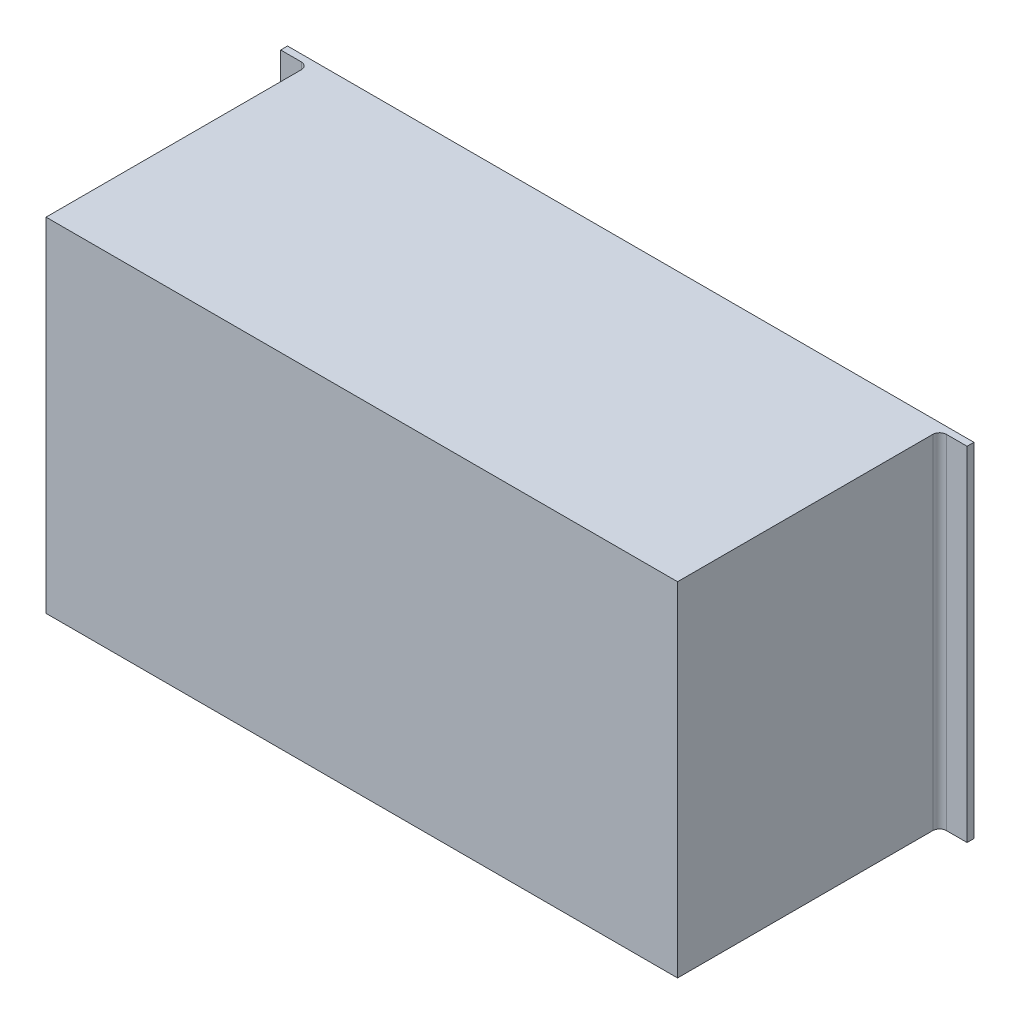
from build123d import *

# Parameters (mm, degrees)
IZIM1_W                     = 920
IZIM1_H                     = 500
Y_KSEKLIK_EKSTR_ZYON1_DEPTH = 380
BO_ALTMA1_T                 = -0.6
IZIM2_W                     = 920
IZIM2_H                     = 500
Y_KSEKLIK_EKSTR_ZYON2_DEPTH = 1.8
IZIM3_W                     = 1000
IZIM3_H                     = 500
Y_KSEKLIK_EKSTR_ZYON3_DEPTH = 10
RADYUS1_R                   = 10
IZIM4_W                     = 918.8
IZIM4_H                     = 498.8
KES_EKSTR_ZYON1_DEPTH       = 5
RADYUS2_R                   = 20
IZIM5_W                     = 920
IZIM5_H                     = 500
KES_EKSTR_ZYON2_DEPTH       = 0.0001


with BuildPart() as part:
    # Çizim1 → Yükseklik-Ekstrüzyon1 (new body)
    with BuildSketch(Plane.XY):
        with Locations((460, 250)):
            Rectangle(IZIM1_W, IZIM1_H)
    extrude(amount=Y_KSEKLIK_EKSTR_ZYON1_DEPTH)

    # İç Boşaltma1
    bo_altma1_openings = [part.faces().sort_by_distance(p)[0] for p in [
        (460, 250, 380),
    ]]
    offset(amount=BO_ALTMA1_T, openings=bo_altma1_openings, kind=Kind.INTERSECTION)

    # Çizim2 → Yükseklik-Ekstrüzyon2 (add)
    with BuildSketch(Plane.XY.offset(380)):
        with Locations((460, 250)):
            Rectangle(IZIM2_W, IZIM2_H)
    extrude(amount=Y_KSEKLIK_EKSTR_ZYON2_DEPTH)

    # Çizim3 → Yükseklik-Ekstrüzyon3 (add)
    with BuildSketch(Plane(origin=(0, 0, 0), x_dir=(-1, 0, 0), z_dir=(0, 0, -1))):
        with Locations((-460, 250)):
            Rectangle(IZIM3_W, IZIM3_H)
    extrude(amount=Y_KSEKLIK_EKSTR_ZYON3_DEPTH)

    # Radyus1
    radyus1_edges = [part.edges().sort_by_distance(p)[0] for p in [
        (0, 250, 0),
        (920, 250, 0),
    ]]
    fillet(radyus1_edges, radius=RADYUS1_R)

    # Çizim4 → Kes-Ekstrüzyon1 (cut)
    with BuildSketch(Plane.XY.offset(0.6)):
        with Locations((460, 250)):
            Rectangle(IZIM4_W, IZIM4_H)
    extrude(amount=-KES_EKSTR_ZYON1_DEPTH, mode=Mode.SUBTRACT)

    # Radyus2
    radyus2_edges = [part.edges().sort_by_distance(p)[0] for p in [
        (919.4, 250, -4.4),
        (460, 0.6, -4.4),
        (0.6, 250, -4.4),
        (460, 499.4, -4.4),
    ]]
    fillet(radyus2_edges, radius=RADYUS2_R)

    # Çizim5 → Kes-Ekstrüzyon2 (cut)
    with BuildSketch(Plane(origin=(0, 0, -10), x_dir=(-1, 0, 0), z_dir=(0, 0, -1))):
        with Locations((-460, 250)):
            Rectangle(IZIM5_W, IZIM5_H)
    extrude(amount=-KES_EKSTR_ZYON2_DEPTH, mode=Mode.SUBTRACT)


solid = part.part
